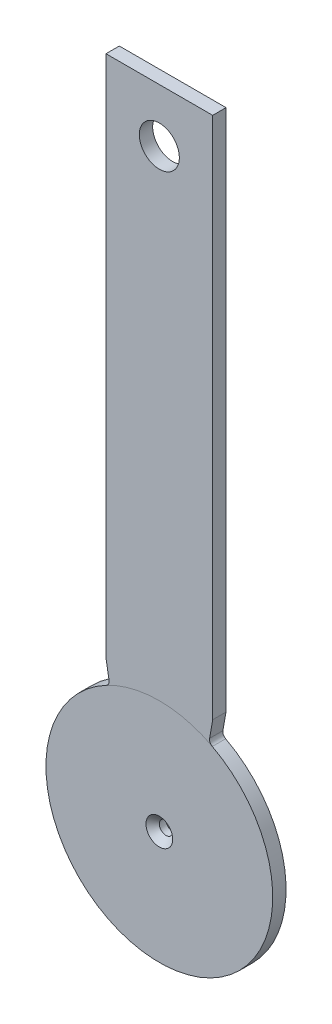
from build123d import *

# Parameters (mm, degrees)
BOSS_EXTRUDE1_DEPTH      = 1.5875
BOSS_EXTRUDE1_DEPTH_BACK = 1.5875
SKETCH3_R                = 1.5875
SKETCH3_R_2              = 4.7625
CHAMFER1_SIZE            = 1.5875


with BuildPart() as part:
    # Sketch3 → Boss-Extrude1 (new, two sides: drawn at the far end of the back side and taken through both)
    with BuildSketch(Plane.XY.offset(-BOSS_EXTRUDE1_DEPTH_BACK)):
        with BuildLine():
            Line((-12.7, 29.413320739), (-11.957294154, 25.201226576))
            ThreePointArc((-11.957294154, 25.201226576), (-12.067180073, 24.422634348), (-12.614382022, 23.857965597))
            ThreePointArc((-12.614382022, 23.857965597), (0, -26.9875), (12.614382022, 23.857965597))
            ThreePointArc((12.614382022, 23.857965597), (12.067180073, 24.422634348), (11.957294154, 25.201226576))
            Line((11.957294154, 25.201226576), (12.7, 29.413320739))
            Line((12.7, 29.413320739), (12.7, 153.9875))
            Line((12.7, 153.9875), (-12.7, 153.9875))
            Line((-12.7, 153.9875), (-12.7, 29.413320739))
        make_face()
        Circle(SKETCH3_R, mode=Mode.SUBTRACT)
        with Locations((0, 141.2875)):
            Circle(SKETCH3_R_2, mode=Mode.SUBTRACT)
    extrude(amount=BOSS_EXTRUDE1_DEPTH + BOSS_EXTRUDE1_DEPTH_BACK)

    # Chamfer1
    chamfer1_edges = [part.edges().sort_by_distance(p)[0] for p in [
        (-1.5875, 0, 1.5875),
    ]]
    chamfer(chamfer1_edges, length=CHAMFER1_SIZE)


solid = part.part
